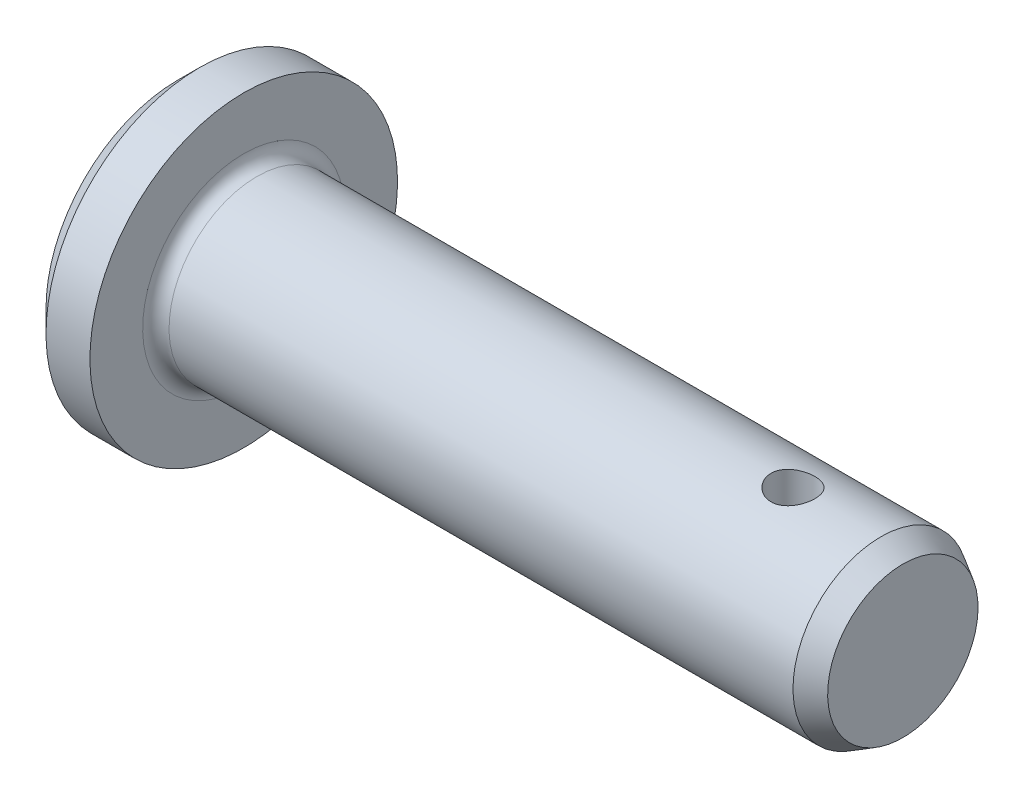
from build123d import *

# Parameters (mm, degrees)
VERRUNDUNG1_R                               = 0.6
SCHNITT_LINEAR_AUSTRAGEN1_REACH             = 9
SKIZZE2_R                                   = 1
SCHNITT_LINEAR_AUSTRAGEN1_DIRECTION_2_REACH = 9


with BuildPart() as part:
    # Skizze1 → Rotation1 (revolve)
    with BuildSketch(Plane.XY):
        Polygon((-3, 0), (-3, 6), (-2, 7), (0, 7), (0, 4), (29, 4), (30, 3.422649731), (30, 0), align=None)
    revolve(axis=Axis((30, 0, 0), (-1, 0, 0)))

    # Verrundung1
    verrundung1_edges = [part.edges().sort_by_distance(p)[0] for p in [
        (0, -4, 0),
    ]]
    fillet(verrundung1_edges, radius=VERRUNDUNG1_R)

    # Skizze2 → Schnitt-Linear austragen1 (cut, up to next)
    with BuildSketch(Plane(origin=(0, 0, 0), x_dir=(1, 0, 0), z_dir=(0, 1, 0)), mode=Mode.PRIVATE) as schnitt_linear_austragen1_sk1:
        with Locations((25, 0)):
            Circle(SKIZZE2_R)
    schnitt_linear_austragen1_tool1 = extrude(schnitt_linear_austragen1_sk1.sketch, amount=-SCHNITT_LINEAR_AUSTRAGEN1_REACH, mode=Mode.PRIVATE) & part.part
    add(schnitt_linear_austragen1_tool1.solids().sort_by_distance((25, 0, 0))[0], mode=Mode.SUBTRACT)

    # Skizze2 → Schnitt-Linear austragen1 direction 2 (cut, up to next)
    with BuildSketch(Plane(origin=(0, 0, 0), x_dir=(1, 0, 0), z_dir=(0, 1, 0)), mode=Mode.PRIVATE) as schnitt_linear_austragen1_direction_2_sk1:
        with Locations((25, 0)):
            Circle(SKIZZE2_R)
    schnitt_linear_austragen1_direction_2_tool1 = extrude(schnitt_linear_austragen1_direction_2_sk1.sketch, amount=SCHNITT_LINEAR_AUSTRAGEN1_DIRECTION_2_REACH, mode=Mode.PRIVATE) & part.part
    add(schnitt_linear_austragen1_direction_2_tool1.solids().sort_by_distance((25, 0, 0))[0], mode=Mode.SUBTRACT)


solid = part.part
